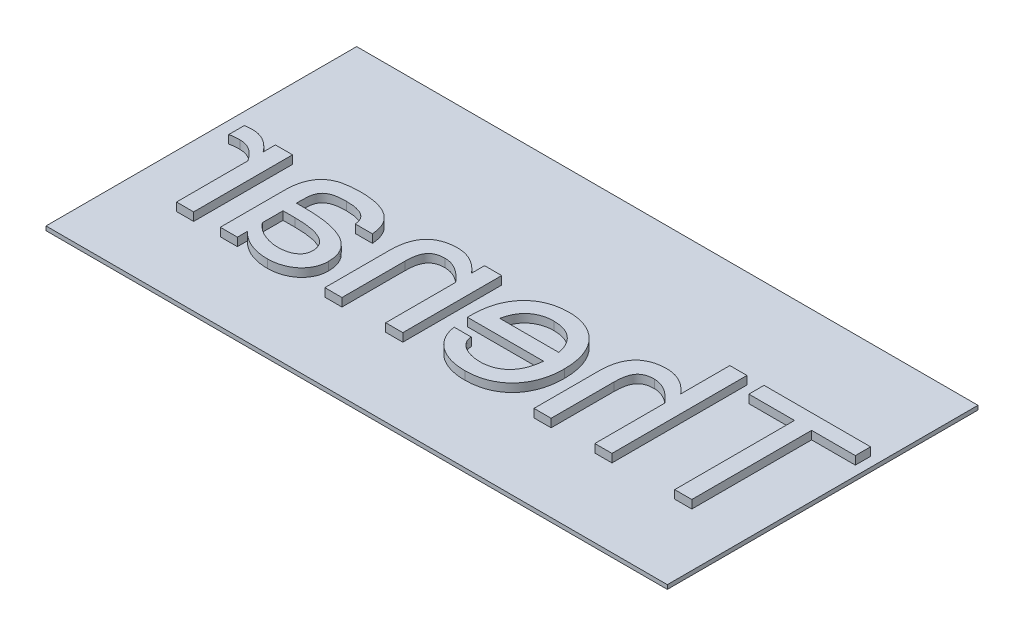
from build123d import *

# Parameters (mm, degrees)
SKETCH1_W           = 30
SKETCH1_H           = 15
BOSS_EXTRUDE1_DEPTH = 0.2
BOSS_EXTRUDE2_DEPTH = 0.4


with BuildPart() as part:
    # Sketch1 → Boss-Extrude1 (new body)
    with BuildSketch(Plane(origin=(0, 0, 0), x_dir=(1, 0, 0), z_dir=(0, 1, 0))):
        Rectangle(SKETCH1_W, SKETCH1_H)
    extrude(amount=BOSS_EXTRUDE1_DEPTH)

    # Sketch2 → Boss-Extrude2 (add)
    with BuildSketch(Plane(origin=(0, 0.2, 0), x_dir=(1, 0, 0), z_dir=(0, 1, 0))):
        Polygon((9.400378492, 2.035985023), (11.603686884, 2.035985023), (11.603686884, -3.747699506), (12.429927531, -3.747699506), (12.429927531, 2.035985023), (14.541431407, 2.035985023), (14.541431407, 2.770421153), (9.400378492, 2.770421153), align=None)
        with BuildLine():
            add(Edge.make_bspline(
                [(7.747897198, 0.39928263), (7.697403057, 0.457283248), (7.599310418, 0.569958374), (7.437155977, 0.716263809), (7.271742276, 0.841377302), (7.100363487, 0.942450445), (6.924388158, 1.020122598), (6.745218547, 1.07713728), (6.56145587, 1.111015433), (6.437428619, 1.115624725), (6.37513279, 1.117939859)],
                knots=[0, 0, 0, 0, 1.151398565, 2.236768881, 3.265638587, 4.254825494, 5.210732226, 6.142076654, 7.066810914, 8, 8, 8, 8], degree=3))
            add(Edge.make_bspline(
                [(6.37513279, 1.117939859), (6.311971051, 1.116489732), (6.189141378, 1.113669693), (6.010901932, 1.094007961), (5.845408713, 1.059301592), (5.691223556, 1.012906878), (5.550839809, 0.948448668), (5.42013822, 0.874622732), (5.302897953, 0.784802986), (5.199206991, 0.680330387), (5.106670181, 0.563041242), (5.025393219, 0.432230839), (4.961207465, 0.285879623), (4.903524247, 0.128378502), (4.861551348, -0.043932809), (4.832046951, -0.230094373), (4.812794607, -0.429424361), (4.811050393, -0.567009025), (4.810152675, -0.637821516)],
                knots=[0, 0, 0, 0, 1.124534611, 2.186865361, 3.186963993, 4.132071078, 5.046585292, 5.931456049, 6.79983362, 7.666665847, 8.54549618, 9.455123626, 10.399923934, 11.385459636, 12.438471516, 13.551117267, 14.739601638, 16, 16, 16, 16], degree=3))
            Line((4.810152675, -0.637821516), (4.810152675, -3.747699506))
            Line((4.810152675, -3.747699506), (5.636393322, -3.747699506))
            Line((5.636393322, -3.747699506), (5.636393322, -0.705240457))
            add(Edge.make_bspline(
                [(5.636393322, -0.705240457), (5.636762708, -0.658359581), (5.637476036, -0.567826949), (5.648013515, -0.437137544), (5.663317886, -0.316881162), (5.684550958, -0.206428495), (5.712963866, -0.106626551), (5.747061819, -0.017064333), (5.787707775, 0.062035549), (5.834899908, 0.131026874), (5.889298124, 0.191436598), (5.951237589, 0.243686307), (6.022481623, 0.286221157), (6.10010243, 0.322663535), (6.186102795, 0.349524997), (6.279178217, 0.369712949), (6.380603838, 0.380866414), (6.450654601, 0.382602491), (6.487019544, 0.383503729)],
                knots=[0, 0, 0, 0, 1.408983357, 2.720916993, 3.938674567, 5.052202663, 6.098673913, 7.054327514, 7.928687407, 8.765987802, 9.559839331, 10.365959322, 11.191830154, 12.047196836, 12.938177023, 13.893938724, 14.906695721, 16, 16, 16, 16], degree=3))
            add(Edge.make_bspline(
                [(6.487019544, 0.383503729), (6.539349433, 0.381387818), (6.645223956, 0.377106879), (6.80332646, 0.338419473), (6.961774986, 0.279371069), (7.120752355, 0.19654245), (7.278571415, 0.089086867), (7.436506544, -0.040981039), (7.595292671, -0.193981511), (7.695671566, -0.308541768), (7.747897198, -0.368145749)],
                knots=[0, 0, 0, 0, 0.828331744, 1.675891721, 2.565608118, 3.504577154, 4.509357774, 5.58653438, 6.744310096, 8, 8, 8, 8], degree=3))
            Line((7.747897198, -0.368145749), (7.747897198, -3.747699506))
            Line((7.747897198, -3.747699506), (8.574137845, -3.747699506))
            Line((8.574137845, -3.747699506), (8.574137845, 2.770421153))
            Line((8.574137845, 2.770421153), (7.747897198, 2.770421153))
            Line((7.747897198, 2.770421153), (7.747897198, 0.39928263))
        make_face()
        with BuildLine():
            add(Edge.make_bspline(
                [(1.559699019, -3.839504023), (1.644918329, -3.837798076), (1.812142181, -3.834450536), (2.056901046, -3.801556555), (2.290605249, -3.750733579), (2.511758435, -3.677585112), (2.719197334, -3.583873189), (2.912380317, -3.471969221), (3.089954996, -3.340657651), (3.251496759, -3.190458521), (3.397192792, -3.021919244), (3.524960102, -2.834357199), (3.635505398, -2.629444085), (3.729714174, -2.407529918), (3.801704484, -2.167798422), (3.855156755, -1.912125239), (3.88697428, -1.640350273), (3.890367904, -1.45362867), (3.892107512, -1.357913191)],
                knots=[0, 0, 0, 0, 1.062219039, 2.084367486, 3.07392373, 4.041258294, 4.983342029, 5.907882117, 6.820227382, 7.731597815, 8.653249009, 9.592687073, 10.555896053, 11.552630547, 12.593837903, 13.672087018, 14.80668705, 16, 16, 16, 16], degree=3))
            add(Edge.make_bspline(
                [(3.892107512, -1.357913191), (3.890462455, -1.264087334), (3.887246391, -1.080659115), (3.853877218, -0.813214473), (3.805549761, -0.559690184), (3.732957079, -0.322291009), (3.642896732, -0.10079436), (3.535244741, 0.103422565), (3.41130992, 0.290416734), (3.269817206, 0.458726185), (3.113738718, 0.610120081), (2.941029855, 0.741095457), (2.755442234, 0.855342699), (2.555043196, 0.94952612), (2.343212377, 1.026559503), (2.118687732, 1.0783849), (1.884501479, 1.113248124), (1.724313698, 1.11635882), (1.642896862, 1.117939859)],
                knots=[0, 0, 0, 0, 1.194278821, 2.334798163, 3.427514766, 4.47738058, 5.490580452, 6.468470696, 7.412559819, 8.341923242, 9.263533905, 10.175762415, 11.096890138, 12.033882821, 12.991155352, 13.961527717, 14.963928695, 16, 16, 16, 16], degree=3))
            add(Edge.make_bspline(
                [(1.642896862, 1.117939859), (1.558638606, 1.116216199), (1.393803702, 1.112844193), (1.152638765, 1.080405808), (0.924392895, 1.02781075), (0.709014393, 0.954289575), (0.507903406, 0.861211932), (0.321609326, 0.748812347), (0.151099644, 0.61755475), (-0.003151188, 0.466804886), (-0.142453451, 0.299544566), (-0.263702687, 0.113322652), (-0.368913504, -0.089097901), (-0.454048838, -0.309823399), (-0.523658505, -0.545607393), (-0.571703515, -0.797822594), (-0.60055993, -1.06556676), (-0.604362671, -1.249299015), (-0.606313789, -1.343568735)],
                knots=[0, 0, 0, 0, 1.071488481, 2.096158999, 3.089229813, 4.047250668, 4.986212776, 5.903242805, 6.809720246, 7.717421554, 8.641946854, 9.573291485, 10.539160056, 11.538897283, 12.578393797, 13.662858424, 14.800854634, 16, 16, 16, 16], degree=3))
            Line((-0.606313789, -1.343568735), (-0.606313789, -1.544391114))
            Line((-0.606313789, -1.544391114), (3.065866865, -1.544391114))
            add(Edge.make_bspline(
                [(3.065866865, -1.544391114), (3.059643483, -1.608586511), (3.04755389, -1.733293006), (3.01425625, -1.913125808), (2.970157297, -2.080214262), (2.9143407, -2.234510585), (2.846846365, -2.375686944), (2.768662774, -2.503867726), (2.683292666, -2.62050547), (2.587717058, -2.723797772), (2.482213329, -2.812405066), (2.369938334, -2.890424165), (2.249886216, -2.956932565), (2.122156926, -3.011626574), (1.986791275, -3.052769335), (1.846167438, -3.082580116), (1.700353174, -3.102317429), (1.601363124, -3.104141541), (1.551092345, -3.105067892)],
                knots=[0, 0, 0, 0, 1.273369465, 2.473657805, 3.607579324, 4.683092007, 5.709513293, 6.6926187, 7.644567901, 8.560029563, 9.464514304, 10.360429293, 11.256593113, 12.170494716, 13.099495153, 14.045994936, 15.007684551, 16, 16, 16, 16], degree=3))
            add(Edge.make_bspline(
                [(1.551092345, -3.105067892), (1.477272423, -3.102677119), (1.329020902, -3.097875763), (1.11086313, -3.056126496), (0.902587841, -2.992471681), (0.742785814, -2.915037038), (0.628815477, -2.840771348), (0.553648351, -2.777859216), (0.485285375, -2.710622739), (0.426719863, -2.635841099), (0.376688781, -2.555297096), (0.341191769, -2.467994781), (0.318993018, -2.375011177), (0.314195151, -2.311461141), (0.311731375, -2.278827245)],
                knots=[0, 0, 0, 0, 1.617967171, 3.249340894, 4.854851871, 6.384035311, 7.125824405, 7.833537815, 8.530680149, 9.22521397, 9.912343252, 10.603781598, 11.283020909, 12, 12, 12, 12], degree=3))
            Line((0.311731375, -2.278827245), (-0.514509272, -2.278827245))
            add(Edge.make_bspline(
                [(-0.514509272, -2.278827245), (-0.504278643, -2.339823358), (-0.484153623, -2.459810901), (-0.432983967, -2.632716071), (-0.367504065, -2.795582335), (-0.285004803, -2.946427584), (-0.189637042, -3.086503183), (-0.082464494, -3.215731516), (0.037763653, -3.33235307), (0.168304222, -3.438015145), (0.311573787, -3.528528394), (0.462624484, -3.612653487), (0.626793347, -3.679243179), (0.798420502, -3.739774484), (0.979954694, -3.782634767), (1.167502026, -3.816604985), (1.361873858, -3.834669778), (1.493205067, -3.837879113), (1.559699019, -3.839504023)],
                knots=[0, 0, 0, 0, 1.040130317, 2.046075993, 3.027911954, 3.989385549, 4.933560823, 5.87636325, 6.809672687, 7.748516996, 8.697208571, 9.658682165, 10.654111032, 11.674629906, 12.718861601, 13.789218054, 14.88066494, 16, 16, 16, 16], degree=3))
        make_face()
        with BuildLine():
            add(Edge.make_bspline(
                [(0.219926858, -0.809954984), (0.230370547, -0.762013621), (0.250796932, -0.668247061), (0.290091795, -0.532797042), (0.341353452, -0.407808917), (0.398250169, -0.290652564), (0.464383678, -0.183300493), (0.537499951, -0.084575406), (0.620162749, 0.002998693), (0.709367382, 0.082324772), (0.805325255, 0.152644365), (0.908296151, 0.21331869), (1.017771688, 0.26515937), (1.133670394, 0.307547492), (1.25430719, 0.342484065), (1.380068893, 0.366738996), (1.510096824, 0.381359337), (1.598390936, 0.382785068), (1.642896862, 0.383503729)],
                knots=[0, 0, 0, 0, 1.155585608, 2.260162867, 3.316254963, 4.333628064, 5.324476197, 6.281730853, 7.221941036, 8.155314221, 9.090113078, 10.019127865, 10.966192648, 11.938955734, 12.922803134, 13.921111186, 14.952106003, 16, 16, 16, 16], degree=3))
            add(Edge.make_bspline(
                [(1.642896862, 0.383503729), (1.730707815, 0.380066054), (1.902361921, 0.373346038), (2.110193913, 0.325660907), (2.265360474, 0.272576994), (2.373800468, 0.221689765), (2.476156288, 0.161232378), (2.572100531, 0.090917642), (2.661426448, 0.011679302), (2.744267522, -0.076956842), (2.819859887, -0.175339861), (2.887344254, -0.284214241), (2.948405428, -0.400966761), (2.995912569, -0.529277518), (3.039331753, -0.665125128), (3.056883473, -0.760923221), (3.065866865, -0.809954984)],
                knots=[0, 0, 0, 0, 1.804359043, 3.527186844, 4.360795028, 5.174794444, 5.986115733, 6.802488331, 7.617615869, 8.438714252, 9.294424527, 10.164928167, 11.071039355, 11.998880892, 12.975779213, 14, 14, 14, 14], degree=3))
            Line((3.065866865, -0.809954984), (0.219926858, -0.809954984))
        make_face(mode=Mode.SUBTRACT)
        with BuildLine():
            add(Edge.make_bspline(
                [(-2.350599599, 0.39928263), (-2.40109374, 0.457283248), (-2.499186379, 0.569958374), (-2.66134082, 0.716263809), (-2.826754521, 0.841377302), (-2.99813331, 0.942450445), (-3.174108638, 1.020122598), (-3.35327825, 1.07713728), (-3.537040927, 1.111015433), (-3.661068177, 1.115624725), (-3.723364007, 1.117939859)],
                knots=[0, 0, 0, 0, 1.151398565, 2.236768881, 3.265638587, 4.254825494, 5.210732226, 6.142076654, 7.066810914, 8, 8, 8, 8], degree=3))
            add(Edge.make_bspline(
                [(-3.723364007, 1.117939859), (-3.786525746, 1.116489732), (-3.909355419, 1.113669693), (-4.087594865, 1.094007961), (-4.253088084, 1.059301592), (-4.407273241, 1.012906878), (-4.547656988, 0.948448668), (-4.678358577, 0.874622732), (-4.795598844, 0.784802986), (-4.899289806, 0.680330387), (-4.991826616, 0.563041242), (-5.073103578, 0.432230839), (-5.137289332, 0.285879623), (-5.194972549, 0.128378502), (-5.236945448, -0.043932809), (-5.266449846, -0.230094373), (-5.28570219, -0.429424361), (-5.287446404, -0.567009025), (-5.288344122, -0.637821516)],
                knots=[0, 0, 0, 0, 1.124534611, 2.186865361, 3.186963993, 4.132071078, 5.046585292, 5.931456049, 6.79983362, 7.666665847, 8.54549618, 9.455123626, 10.399923934, 11.385459636, 12.438471516, 13.551117267, 14.739601638, 16, 16, 16, 16], degree=3))
            Line((-5.288344122, -0.637821516), (-5.288344122, -3.747699506))
            Line((-5.288344122, -3.747699506), (-4.462103475, -3.747699506))
            Line((-4.462103475, -3.747699506), (-4.462103475, -0.705240457))
            add(Edge.make_bspline(
                [(-4.462103475, -0.705240457), (-4.461734089, -0.658359581), (-4.461020761, -0.567826949), (-4.450483281, -0.437137544), (-4.435178911, -0.316881162), (-4.413945839, -0.206428495), (-4.385532931, -0.106626551), (-4.351434978, -0.017064333), (-4.310789022, 0.062035549), (-4.263596889, 0.131026874), (-4.209198673, 0.191436598), (-4.147259207, 0.243686307), (-4.076015174, 0.286221157), (-3.998394367, 0.322663535), (-3.912394002, 0.349524997), (-3.81931858, 0.369712949), (-3.717892959, 0.380866414), (-3.647842196, 0.382602491), (-3.611477253, 0.383503729)],
                knots=[0, 0, 0, 0, 1.408983357, 2.720916993, 3.938674567, 5.052202663, 6.098673913, 7.054327514, 7.928687407, 8.765987802, 9.559839331, 10.365959322, 11.191830154, 12.047196836, 12.938177023, 13.893938724, 14.906695721, 16, 16, 16, 16], degree=3))
            add(Edge.make_bspline(
                [(-3.611477253, 0.383503729), (-3.559147364, 0.381387818), (-3.45327284, 0.377106879), (-3.295170337, 0.338419473), (-3.136721811, 0.279371069), (-2.977744442, 0.19654245), (-2.819925382, 0.089086867), (-2.661990253, -0.040981039), (-2.503204126, -0.193981511), (-2.40282523, -0.308541768), (-2.350599599, -0.368145749)],
                knots=[0, 0, 0, 0, 0.828331744, 1.675891721, 2.565608118, 3.504577154, 4.509357774, 5.58653438, 6.744310096, 8, 8, 8, 8], degree=3))
            Line((-2.350599599, -0.368145749), (-2.350599599, -3.747699506))
            Line((-2.350599599, -3.747699506), (-1.524358952, -3.747699506))
            Line((-1.524358952, -3.747699506), (-1.524358952, 1.026135343))
            Line((-1.524358952, 1.026135343), (-2.350599599, 1.026135343))
            Line((-2.350599599, 1.026135343), (-2.350599599, 0.39928263))
        make_face()
        with BuildLine():
            add(Edge.make_bspline(
                [(-9.511351873, -3.268594687), (-9.456445364, -3.321430665), (-9.34788209, -3.425900006), (-9.168298427, -3.560438711), (-8.980235069, -3.677320026), (-8.778724671, -3.767978947), (-8.568981018, -3.842585976), (-8.348005408, -3.893184622), (-8.117121596, -3.926308047), (-7.959401426, -3.929619474), (-7.878952817, -3.931308539)],
                knots=[0, 0, 0, 0, 1.008693959, 1.994428726, 2.966821227, 3.936237643, 4.915948889, 5.911668753, 6.934801152, 8, 8, 8, 8], degree=3))
            add(Edge.make_bspline(
                [(-7.878952817, -3.931308539), (-7.823912692, -3.930340593), (-7.715416103, -3.928432551), (-7.555584749, -3.909290403), (-7.40212719, -3.877766971), (-7.255246347, -3.834724573), (-7.116418575, -3.780650256), (-6.986875493, -3.715338388), (-6.865058388, -3.642317533), (-6.753175111, -3.558004571), (-6.652757395, -3.462329638), (-6.561470203, -3.359646188), (-6.484208132, -3.246030396), (-6.415842706, -3.126032021), (-6.362273633, -2.996040978), (-6.32603347, -2.857973925), (-6.301648523, -2.713367335), (-6.299359597, -2.614590776), (-6.298193801, -2.564281913)],
                knots=[0, 0, 0, 0, 1.129919587, 2.227328197, 3.299987898, 4.343994437, 5.36696243, 6.355025484, 7.319983149, 8.280333349, 9.225044012, 10.16448364, 11.09603842, 12.041208263, 12.996726989, 13.973355049, 14.967789474, 16, 16, 16, 16], degree=3))
            add(Edge.make_bspline(
                [(-6.298193801, -2.564281913), (-6.300410857, -2.497204032), (-6.304746318, -2.366032957), (-6.338147234, -2.176043654), (-6.392806068, -1.998993537), (-6.469197165, -1.834769614), (-6.569508422, -1.684540413), (-6.691279256, -1.54721812), (-6.834942965, -1.422776957), (-7.001250563, -1.312602112), (-7.18893996, -1.215071927), (-7.398038738, -1.130743892), (-7.628878611, -1.059326588), (-7.881478665, -1.000648392), (-8.156336447, -0.957709066), (-8.452018609, -0.924054177), (-8.770008107, -0.906391518), (-8.98919513, -0.903338296), (-9.102534886, -0.9017595)],
                knots=[0, 0, 0, 0, 0.876846711, 1.714677391, 2.513691117, 3.294138438, 4.074560709, 4.86750791, 5.687508358, 6.552909544, 7.470289477, 8.449157088, 9.497349241, 10.627342591, 11.837292144, 13.133411966, 14.517711573, 16, 16, 16, 16], degree=3))
            Line((-9.102534886, -0.9017595), (-9.511351873, -0.9017595))
            add(Edge.make_bspline(
                [(-9.511351873, -0.9017595), (-9.510829292, -0.80466873), (-9.509845093, -0.621813765), (-9.49690436, -0.400745864), (-9.47969731, -0.240771753), (-9.453964263, -0.134147523), (-9.416467924, -0.037329257), (-9.368566298, 0.050486657), (-9.308269038, 0.130409497), (-9.228187508, 0.195752314), (-9.135302911, 0.254480308), (-9.024293246, 0.301421922), (-8.893882361, 0.338881362), (-8.741488606, 0.365254328), (-8.565876291, 0.380287739), (-8.441286703, 0.382389878), (-8.375270983, 0.383503729)],
                knots=[0, 0, 0, 0, 1.976405761, 3.722244706, 4.50709953, 5.248489405, 5.948118427, 6.614729878, 7.28070128, 7.971263746, 8.70597661, 9.512566779, 10.4151892, 11.463537227, 12.65601599, 14, 14, 14, 14], degree=3))
            add(Edge.make_bspline(
                [(-8.375270983, 0.383503729), (-8.28763328, 0.381611472), (-8.122589162, 0.37804787), (-7.89131601, 0.343934887), (-7.692443986, 0.288882708), (-7.527163994, 0.207445254), (-7.393493366, 0.10393495), (-7.297406138, -0.027546498), (-7.234767357, -0.181445685), (-7.22257742, -0.292951982), (-7.216238965, -0.350932402)],
                knots=[0, 0, 0, 0, 1.367972349, 2.57624037, 3.642091365, 4.577248667, 5.43799677, 6.255031606, 7.0926611, 8, 8, 8, 8], degree=3))
            Line((-7.216238965, -0.350932402), (-6.389998318, -0.350932402))
            add(Edge.make_bspline(
                [(-6.389998318, -0.350932402), (-6.395078801, -0.291497078), (-6.404978106, -0.17568754), (-6.438423464, -0.00846185), (-6.485637788, 0.147348235), (-6.547074129, 0.292360821), (-6.62553922, 0.424414072), (-6.716129428, 0.546830843), (-6.82339253, 0.656008065), (-6.944712215, 0.754120438), (-7.080560423, 0.840394393), (-7.230653414, 0.915015879), (-7.395004971, 0.977999722), (-7.573582278, 1.029370013), (-7.766839104, 1.069424306), (-7.97439332, 1.097358485), (-8.196617499, 1.114965916), (-8.349416027, 1.116926897), (-8.428345469, 1.117939859)],
                knots=[0, 0, 0, 0, 1.011374519, 1.970660019, 2.886717708, 3.769711183, 4.635053168, 5.486791011, 6.347252636, 7.223926513, 8.128527383, 9.071729985, 10.062962718, 11.110357716, 12.220813927, 13.408159289, 14.661161577, 16, 16, 16, 16], degree=3))
            add(Edge.make_bspline(
                [(-8.428345469, 1.117939859), (-8.50009415, 1.117271461), (-8.639919517, 1.115968871), (-8.84437484, 1.101270152), (-9.037956718, 1.077412692), (-9.220560304, 1.04294172), (-9.392438681, 0.999332826), (-9.549481373, 0.934602126), (-9.694914571, 0.85806454), (-9.824641834, 0.761620497), (-9.94288883, 0.650738115), (-10.044885513, 0.519405038), (-10.134616171, 0.371123846), (-10.20742244, 0.202431008), (-10.26650211, 0.014147449), (-10.309460702, -0.196728606), (-10.332702378, -0.431692602), (-10.335912037, -0.596172486), (-10.33759252, -0.682289328)],
                knots=[0, 0, 0, 0, 1.128893817, 2.200012469, 3.223836039, 4.196355351, 5.123574499, 6.008041986, 6.863185511, 7.702963125, 8.543886091, 9.406445866, 10.311040475, 11.264510836, 12.290185282, 13.411707618, 14.644846036, 16, 16, 16, 16], degree=3))
            Line((-10.33759252, -0.682289328), (-10.33759252, -3.747699506))
            Line((-10.33759252, -3.747699506), (-9.511351873, -3.747699506))
            Line((-9.511351873, -3.747699506), (-9.511351873, -3.268594687))
        make_face()
        with BuildLine():
            Line((-9.511351873, -2.54276523), (-9.511351873, -1.544391114))
            Line((-9.511351873, -1.544391114), (-8.933270309, -1.544391114))
            add(Edge.make_bspline(
                [(-8.933270309, -1.544391114), (-8.860107121, -1.54544809), (-8.71849393, -1.547493951), (-8.513095994, -1.556619422), (-8.322157847, -1.575500861), (-8.145414692, -1.60085428), (-7.983018404, -1.633717014), (-7.83401724, -1.673220495), (-7.699701281, -1.722403701), (-7.577692243, -1.775948081), (-7.471058566, -1.839440028), (-7.378258939, -1.909817283), (-7.299642393, -1.987717321), (-7.236089657, -2.073642426), (-7.184488285, -2.165663349), (-7.150891506, -2.266523665), (-7.128044088, -2.373909502), (-7.125661393, -2.448442062), (-7.124434448, -2.486821852)],
                knots=[0, 0, 0, 0, 1.543140038, 2.986870709, 4.33442679, 5.587962877, 6.750812624, 7.827152642, 8.835143634, 9.764837363, 10.632994109, 11.445800055, 12.215885998, 12.95806704, 13.693642222, 14.430322495, 15.191710374, 16, 16, 16, 16], degree=3))
            add(Edge.make_bspline(
                [(-7.124434448, -2.486821852), (-7.127528832, -2.541277858), (-7.13348258, -2.646053928), (-7.185504365, -2.793457134), (-7.273252837, -2.919107545), (-7.39414656, -3.021480997), (-7.541454138, -3.101296464), (-7.712324391, -3.156080486), (-7.903337999, -3.191251597), (-8.038006293, -3.194941742), (-8.108464108, -3.196872408)],
                knots=[0, 0, 0, 0, 0.955271913, 1.837990817, 2.707806138, 3.619626737, 4.597815716, 5.634575256, 6.76242095, 8, 8, 8, 8], degree=3))
            add(Edge.make_bspline(
                [(-8.108464108, -3.196872408), (-8.176990838, -3.194704336), (-8.313950697, -3.190371154), (-8.517253635, -3.153979073), (-8.714819149, -3.09899185), (-8.903818605, -3.024023025), (-9.08094064, -2.931088892), (-9.243158243, -2.818901291), (-9.389431286, -2.69069917), (-9.470989098, -2.591739931), (-9.511351873, -2.54276523)],
                knots=[0, 0, 0, 0, 1.02686125, 2.052319889, 3.087383097, 4.097895062, 5.095325332, 6.079761156, 7.049678189, 8, 8, 8, 8], degree=3))
        make_face(mode=Mode.SUBTRACT)
        with BuildLine():
            add(Edge.make_bspline(
                [(-14.009773173, 0.326125906), (-13.977430039, 0.335524047), (-13.908346182, 0.355598164), (-13.793023002, 0.370519369), (-13.6614862, 0.383078058), (-13.567529236, 0.383356325), (-13.517758344, 0.383503729)],
                knots=[0, 0, 0, 0, 0.811760592, 1.733893603, 2.799597893, 4, 4, 4, 4], degree=3))
            add(Edge.make_bspline(
                [(-13.517758344, 0.383503729), (-13.465972737, 0.38110556), (-13.363822971, 0.376375049), (-13.21394654, 0.344463371), (-13.071765178, 0.288605805), (-12.935653859, 0.211734145), (-12.806282449, 0.112418402), (-12.680262474, -0.00624646), (-12.560169862, -0.147457905), (-12.486956046, -0.252266789), (-12.449096396, -0.30646459)],
                knots=[0, 0, 0, 0, 0.935309567, 1.844946122, 2.75273578, 3.68472984, 4.658945774, 5.691481518, 6.806240285, 8, 8, 8, 8], degree=3))
            Line((-12.449096396, -0.30646459), (-12.449096396, -3.747699506))
            Line((-12.449096396, -3.747699506), (-11.622855749, -3.747699506))
            Line((-11.622855749, -3.747699506), (-11.622855749, 1.026135343))
            Line((-11.622855749, 1.026135343), (-12.449096396, 1.026135343))
            Line((-12.449096396, 1.026135343), (-12.449096396, 0.435143769))
            add(Edge.make_bspline(
                [(-12.449096396, 0.435143769), (-12.492018121, 0.489631029), (-12.574935162, 0.594890601), (-12.713105063, 0.732947269), (-12.853616135, 0.852956854), (-13.001781515, 0.948480936), (-13.154183336, 1.025553509), (-13.312928953, 1.077526752), (-13.476023127, 1.113053639), (-13.586901726, 1.116306932), (-13.642555108, 1.117939859)],
                knots=[0, 0, 0, 0, 1.164877259, 2.250333035, 3.277294879, 4.26481857, 5.206507066, 6.139236085, 7.066025311, 8, 8, 8, 8], degree=3))
            add(Edge.make_bspline(
                [(-13.642555108, 1.117939859), (-13.670308155, 1.117881838), (-13.728297052, 1.117760606), (-13.818098853, 1.109011086), (-13.913134391, 1.100596557), (-13.977321666, 1.089249805), (-14.009773173, 1.083513166)],
                knots=[0, 0, 0, 0, 0.901261016, 1.88314931, 2.929772366, 4, 4, 4, 4], degree=3))
            Line((-14.009773173, 1.083513166), (-14.009773173, 0.326125906))
        make_face()
    extrude(amount=BOSS_EXTRUDE2_DEPTH)


solid = part.part
